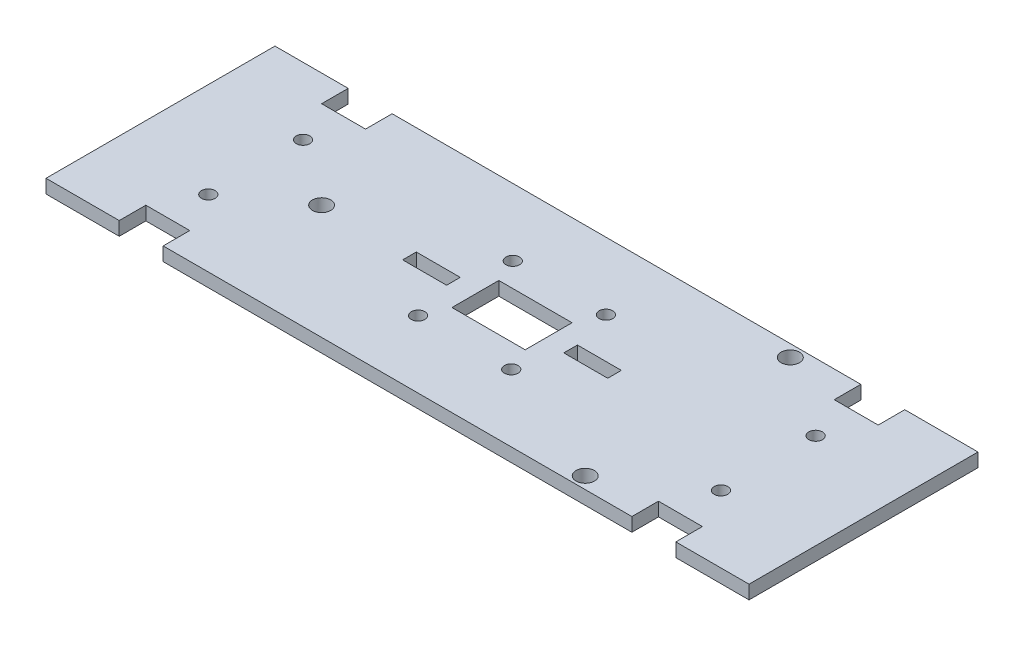
from build123d import *

# Parameters (mm, degrees)
SKETCH2_W                       = 9.525
SKETCH2_H                       = 2.9591
SKETCH2_W_2                     = 15.875
SKETCH2_H_2                     = 10.16
BOSS_EXTRUDE1_DEPTH             = 2.9591
F_4_CLEARANCE_HOLE1_D           = 2.9464
F_4_CLEARANCE_HOLE1_DEPTH       = 3.302
F_4_CLEARANCE_HOLE1_TIP         = 0.885187864
F_4_CLEARANCE_HOLE2_D           = 3.9624
F_4_CLEARANCE_HOLE2_DEPTH       = 3.302
F_4_CLEARANCE_HOLE2_TIP         = 1.190425058
TAP_DRILL_FOR_4_HELICOIL1_D     = 3.9878
TAP_DRILL_FOR_4_HELICOIL1_DEPTH = 5.588
TAP_DRILL_FOR_4_HELICOIL1_TIP   = 1.198055988


with BuildPart() as part:
    # Sketch2 → Boss-Extrude1 (new body)
    with BuildSketch(Plane(origin=(0, 0, 0), x_dir=(1, 0, 0), z_dir=(0, 1, 0))):
        Polygon((-76.2, 24.8158), (-60.325, 24.8158), (-60.325, 19.05), (-50.8, 19.05), (-50.8, 24.8158), (50.8, 24.8158), (50.8, 19.05), (60.325, 19.05), (60.325, 24.8158), (76.2, 24.8158), (76.2, -24.8158), (60.325, -24.8158), (60.325, -19.05), (50.8, -19.05), (50.8, -24.8158), (-50.8, -24.8158), (-50.8, -19.05), (-60.325, -19.05), (-60.325, -24.8158), (-76.2, -24.8158), align=None)
        with Locations((-17.4625, 0)):
            Rectangle(SKETCH2_W, SKETCH2_H, mode=Mode.SUBTRACT)
        with Locations((17.4625, 0)):
            Rectangle(SKETCH2_W, SKETCH2_H, mode=Mode.SUBTRACT)
        Rectangle(SKETCH2_W_2, SKETCH2_H_2, mode=Mode.SUBTRACT)
    extrude(amount=BOSS_EXTRUDE1_DEPTH)

    # #4 Clearance Hole1
    with Locations(Plane(origin=(0, 2.9591, 0), x_dir=(1, 0, 0), z_dir=(0, 1, 0))):
        with Locations((0, 0), (10.0965, 10.264775), (-10.0965, -10.264775), (-10.0965, 10.264775), (10.0965, -10.264775), (55.5625, 10.264775), (-55.5625, -10.264775), (55.5625, -10.264775), (-55.5625, 10.264775)):
            Hole(F_4_CLEARANCE_HOLE1_D / 2, depth=F_4_CLEARANCE_HOLE1_DEPTH)
            with Locations((0, 0, -(F_4_CLEARANCE_HOLE1_DEPTH + F_4_CLEARANCE_HOLE1_TIP / 2))):  # 118° drill point
                Cone(0, F_4_CLEARANCE_HOLE1_D / 2, F_4_CLEARANCE_HOLE1_TIP, mode=Mode.SUBTRACT)

    # #4 Clearance Hole2
    with Locations(Plane(origin=(0, 2.9591, 0), x_dir=(1, 0, 0), z_dir=(0, 1, 0))):
        with Locations((-41.275, 0)):
            Hole(F_4_CLEARANCE_HOLE2_D / 2, depth=F_4_CLEARANCE_HOLE2_DEPTH)
            with Locations((0, 0, -(F_4_CLEARANCE_HOLE2_DEPTH + F_4_CLEARANCE_HOLE2_TIP / 2))):  # 118° drill point
                Cone(0, F_4_CLEARANCE_HOLE2_D / 2, F_4_CLEARANCE_HOLE2_TIP, mode=Mode.SUBTRACT)

    # Tap Drill for #4 Helicoil1
    with Locations(Plane(origin=(0, 0, 0), x_dir=(-1, 0, 0), z_dir=(0, -1, 0))):
        with Locations((-38.1, 22.225), (-38.1, -22.225)):
            Hole(TAP_DRILL_FOR_4_HELICOIL1_D / 2, depth=TAP_DRILL_FOR_4_HELICOIL1_DEPTH)
            with Locations((0, 0, -(TAP_DRILL_FOR_4_HELICOIL1_DEPTH + TAP_DRILL_FOR_4_HELICOIL1_TIP / 2))):  # 118° drill point
                Cone(0, TAP_DRILL_FOR_4_HELICOIL1_D / 2, TAP_DRILL_FOR_4_HELICOIL1_TIP, mode=Mode.SUBTRACT)


solid = part.part
